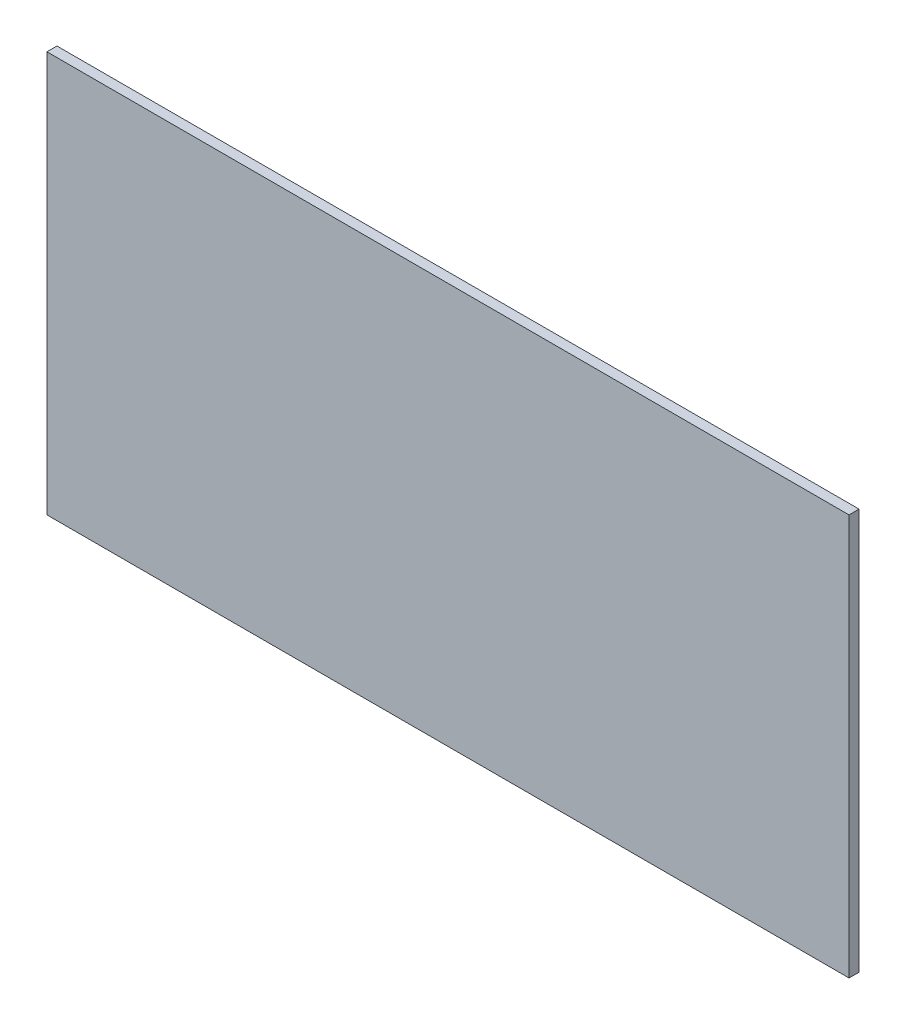
from build123d import *

# Parameters (mm, degrees)
SKETCH1_W           = 254
SKETCH1_H           = 127
BOSS_EXTRUDE1_DEPTH = 1.5875


with BuildPart() as part:
    # Sketch1 → Boss-Extrude1 (new body, symmetric)
    with BuildSketch(Plane.XY):
        Rectangle(SKETCH1_W, SKETCH1_H)
    extrude(amount=BOSS_EXTRUDE1_DEPTH, both=True)


solid = part.part
